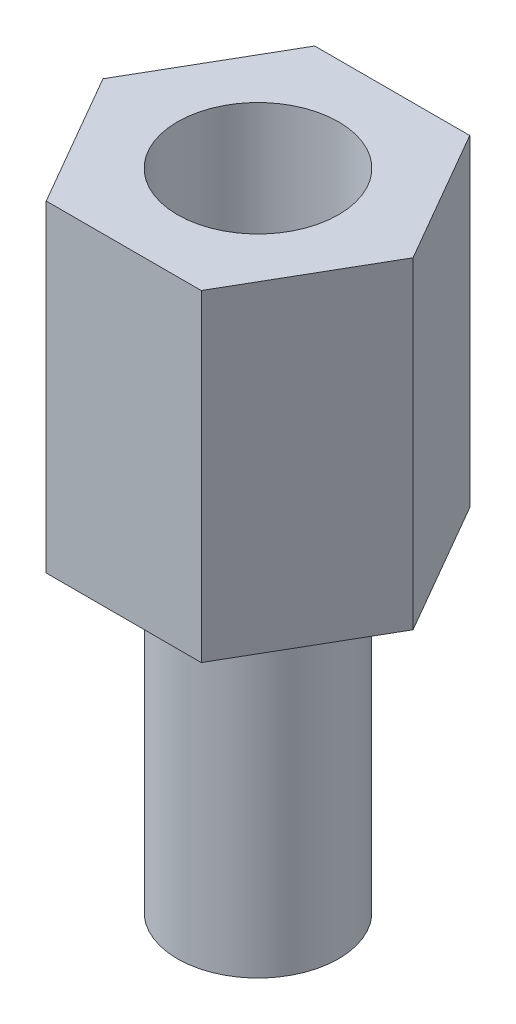
from build123d import *

# Parameters (mm, degrees)
CROQUIS1_R              = 1.5
SALIENTE_EXTRUIR1_DEPTH = 6
CROQUIS2_R              = 1.5
SALIENTE_EXTRUIR2_DEPTH = 6


with BuildPart() as part:
    # Croquis1 → Saliente-Extruir1 (new body)
    with BuildSketch(Plane(origin=(0, 0, 0), x_dir=(1, 0, 0), z_dir=(0, 1, 0))):
        Polygon((1.443375673, -2.5), (2.886751346, 0), (1.443375673, 2.5), (-1.443375673, 2.5), (-2.886751346, 0), (-1.443375673, -2.5), align=None)
        Circle(CROQUIS1_R, mode=Mode.SUBTRACT)
    extrude(amount=SALIENTE_EXTRUIR1_DEPTH)


with BuildPart() as body_2:
    # Croquis2 → Saliente-Extruir2 (new body)
    with BuildSketch(Plane.XZ):
        Circle(CROQUIS2_R)
    extrude(amount=SALIENTE_EXTRUIR2_DEPTH)


solid = Compound([part.part, body_2.part])
